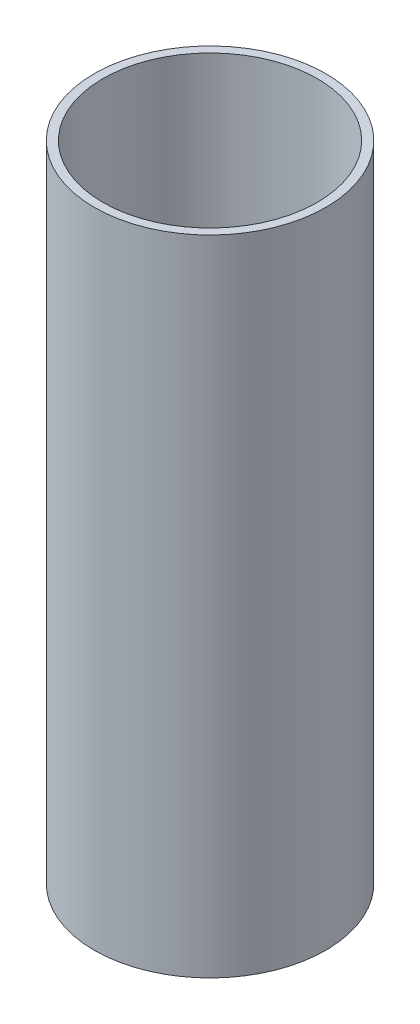
from build123d import *

# Parameters (mm, degrees)
SKETCH1_R           = 27
SKETCH1_R_2         = 25
BOSS_EXTRUDE1_DEPTH = 150


with BuildPart() as part:
    # Sketch1 → Boss-Extrude1 (new body)
    with BuildSketch(Plane(origin=(0, 0, 0), x_dir=(1, 0, 0), z_dir=(0, 1, 0))):
        Circle(SKETCH1_R)
        Circle(SKETCH1_R_2, mode=Mode.SUBTRACT)
    extrude(amount=BOSS_EXTRUDE1_DEPTH)


solid = part.part
